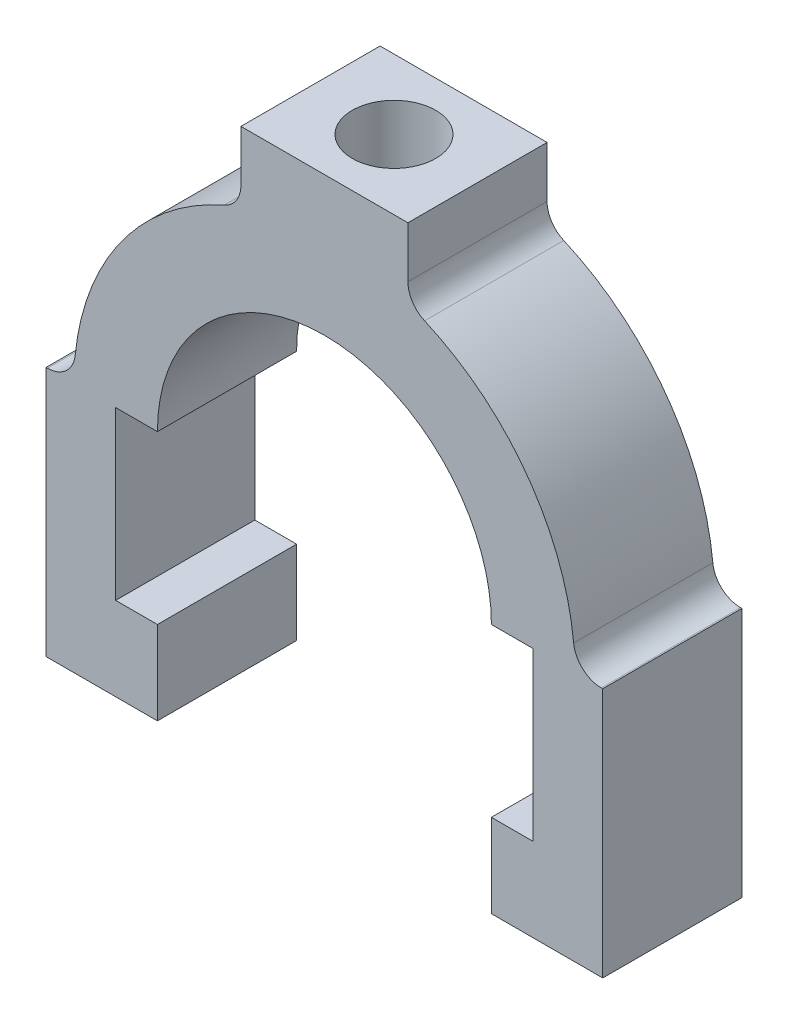
from build123d import *

# Parameters (mm, degrees)
SKETCH1_W           = 80
SKETCH1_H           = 80
BOSS_EXTRUDE1_DEPTH = 20
CUT_EXTRUDE1_DEPTH  = 21
SKETCH3_R           = 24
CUT_EXTRUDE2_DEPTH  = 21
CUT_EXTRUDE3_DEPTH  = 21
SKETCH5_R           = 6
CUT_EXTRUDE4_DEPTH  = 81
FILLET1_R           = 4


with BuildPart() as part:
    # Sketch1 → Boss-Extrude1 (new body)
    with BuildSketch(Plane.XY):
        with Locations((40, 40)):
            Rectangle(SKETCH1_W, SKETCH1_H)
    extrude(amount=-BOSS_EXTRUDE1_DEPTH)

    # Sketch2 → Cut-Extrude1 (cut, through all)
    with BuildSketch(Plane.XY):
        Polygon((16, 0), (64, 0), (64, 12), (70, 12), (70, 36), (10, 36), (10, 12), (16, 12), align=None)
    extrude(amount=-CUT_EXTRUDE1_DEPTH, mode=Mode.SUBTRACT)

    # Sketch3 → Cut-Extrude2 (cut, through all)
    with BuildSketch(Plane.XY):
        with Locations((40, 36)):
            Circle(SKETCH3_R)
    extrude(amount=-CUT_EXTRUDE2_DEPTH, mode=Mode.SUBTRACT)

    # Sketch4 → Cut-Extrude3 (cut, through all)
    with BuildSketch(Plane.XY):
        with BuildLine():
            Line((4, 36), (0, 36))
            Line((0, 36), (0, 80))
            Line((0, 80), (28, 80))
            Line((28, 80), (28, 69.941125497))
            ThreePointArc((28, 69.941125497), (10.606123087, 56.784609691), (4, 36))
        make_face()
        with BuildLine():
            Line((76, 36), (80, 36))
            Line((80, 36), (80, 80))
            Line((80, 80), (52, 80))
            Line((52, 80), (52, 69.941125497))
            ThreePointArc((52, 69.941125497), (69.393876913, 56.784609691), (76, 36))
        make_face()
    extrude(amount=-CUT_EXTRUDE3_DEPTH, mode=Mode.SUBTRACT)

    # Sketch5 → Cut-Extrude4 (cut, through all)
    with BuildSketch(Plane(origin=(0, 80, 0), x_dir=(1, 0, 0), z_dir=(0, 1, 0))):
        with Locations((40, 10)):
            Circle(SKETCH5_R)
    extrude(amount=-CUT_EXTRUDE4_DEPTH, mode=Mode.SUBTRACT)

    # Fillet1
    fillet1_edges = [part.edges().sort_by_distance(p)[0] for p in [
        (76, 36, -10),
        (52, 69.941125497, -10),
        (28, 69.941125497, -10),
        (4, 36, -10),
    ]]
    fillet(fillet1_edges, radius=FILLET1_R)


solid = part.part
